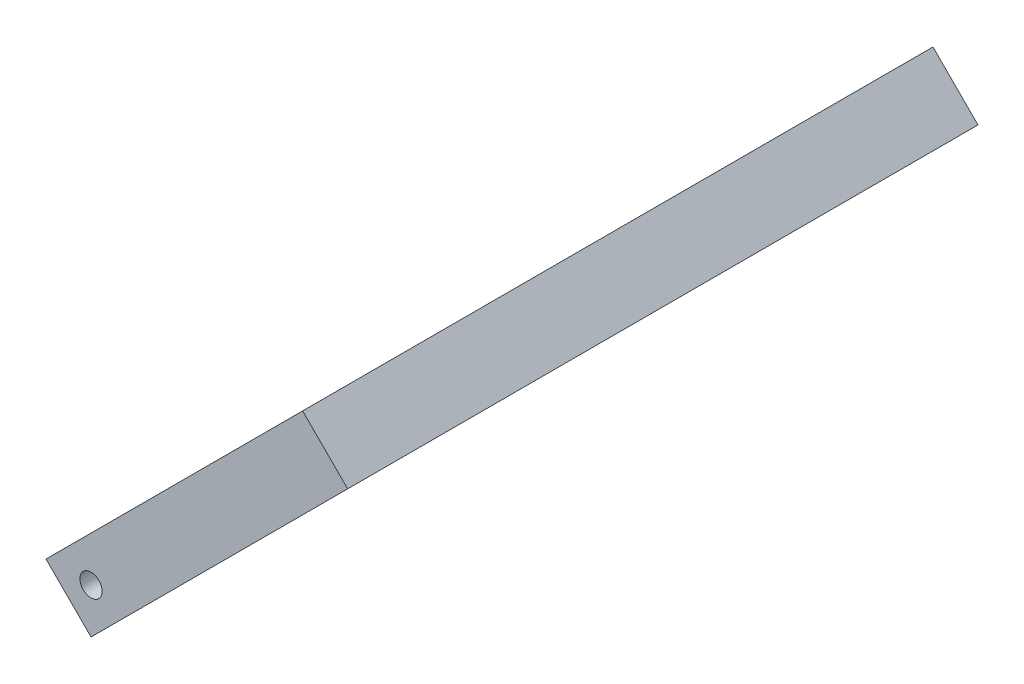
from build123d import *

# Parameters (mm, degrees)
BOSS_EXTRUDE1_DEPTH = 5
SKETCH2_W           = 99
SKETCH2_H           = 10
BOSS_EXTRUDE2_DEPTH = 10
BOSS_EXTRUDE3_DEPTH = 10
SKETCH4_R           = 1.75
CUT_EXTRUDE1_DEPTH  = 100


with BuildPart() as part:
    # Sketch1 → Boss-Extrude1 (new body)
    with BuildSketch(Plane.XY):
        Polygon((67.175144213, 60.104076401), (60.104076401, 67.175144213), (93.338122667, 100.409190479), (100.409190479, 93.338122667), align=None)
    extrude(amount=-BOSS_EXTRUDE1_DEPTH)

    # Sketch2 → Boss-Extrude2 (add)
    with BuildSketch(Plane(origin=(96.873656573, 96.873656573, 0), x_dir=(0, 0, -1), z_dir=(0.707106781, 0.707106781, 0))):
        with Locations((49.5, 0)):
            Rectangle(SKETCH2_W, SKETCH2_H)
    extrude(amount=BOSS_EXTRUDE2_DEPTH)

    # Sketch3 → Boss-Extrude3 (add)
    with BuildSketch(Plane(origin=(3.535533906, -3.535533906, 0), x_dir=(0, 0, -1), z_dir=(0.707106781, -0.707106781, 0))):
        Polygon((5, 100), (22.25340152, 137.000038963), (5, 137.000038963), align=None)
    extrude(amount=-BOSS_EXTRUDE3_DEPTH)

    # Sketch4 → Cut-Extrude1 (cut, through all)
    with BuildSketch(Plane.XY):
        with Locations((67.175144213, 67.175144213)):
            Circle(SKETCH4_R)
    extrude(amount=-CUT_EXTRUDE1_DEPTH, mode=Mode.SUBTRACT)


solid = part.part
